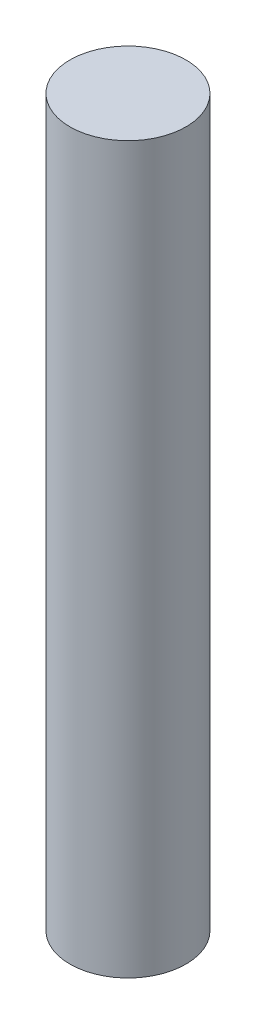
from build123d import *

# Parameters (mm, degrees)
SKETCH1_R           = 10
BOSS_EXTRUDE1_DEPTH = 125


with BuildPart() as part:
    # Sketch1 → Boss-Extrude1 (new body)
    with BuildSketch(Plane(origin=(0, 0, 0), x_dir=(1, 0, 0), z_dir=(0, 1, 0))):
        Circle(SKETCH1_R)
    extrude(amount=BOSS_EXTRUDE1_DEPTH)


solid = part.part
